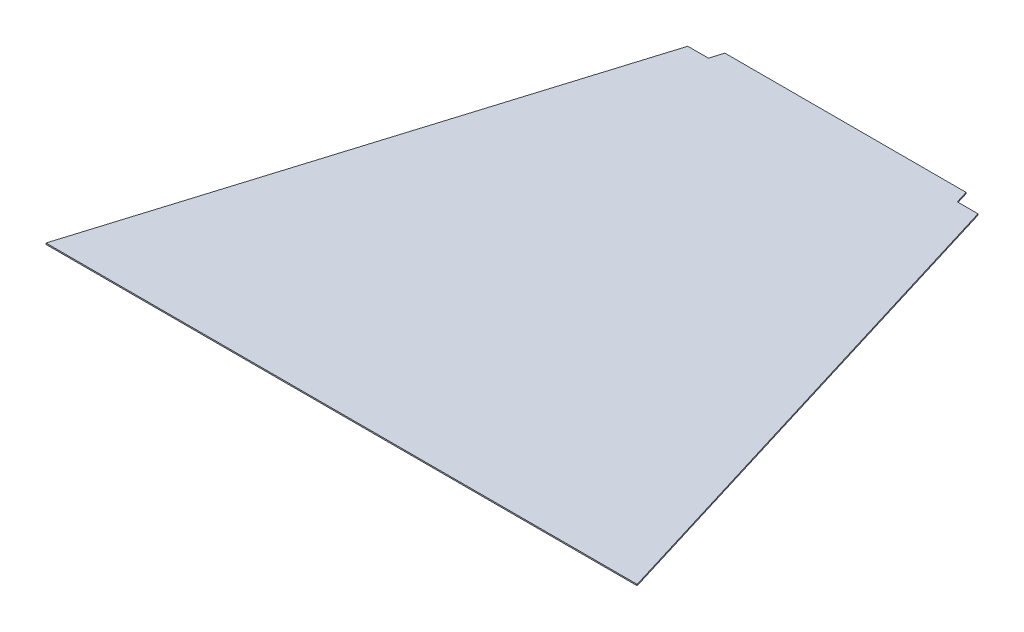
from build123d import *

# Parameters (mm, degrees)
BOSS_EXTRUDE1_DEPTH = 1.5875


with BuildPart() as part:
    # Sketch1 → Boss-Extrude1 (new body)
    with BuildSketch(Plane(origin=(0, 0, 0), x_dir=(1, 0, 0), z_dir=(0, 1, 0))):
        Polygon((-186.400835238, 16.133629032), (-374.916285391, -599.401646952), (365.747714502, -599.401646952), (177.232264348, 16.133629032), (151.324264348, 16.133629032), (146.489528486, 31.919870799), (-155.658099376, 31.919870799), (-160.492835238, 16.133629032), align=None)
    extrude(amount=BOSS_EXTRUDE1_DEPTH)


solid = part.part
